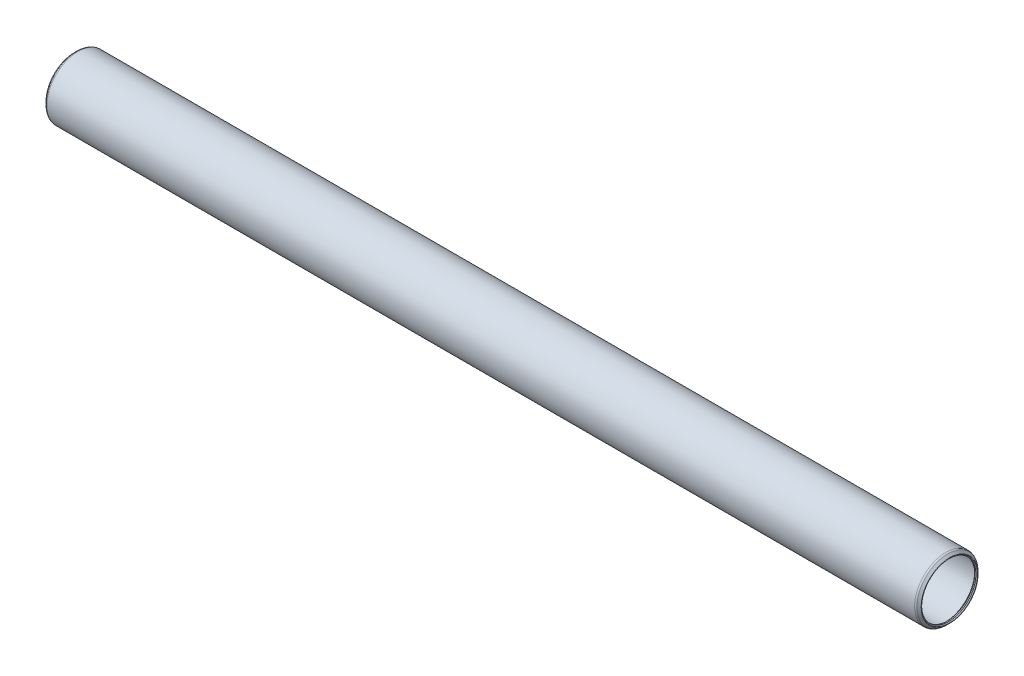
from build123d import *


with BuildPart() as part:
    # Sketch1 → Revolve1 (revolve)
    with BuildSketch(Plane.XY):
        with BuildLine():
            Line((-0.639512806, 9.167562806), (-0.381, 8.90905))
            Line((-0.381, 8.90905), (0, 8.90905))
            Line((0, 8.90905), (0.762, 9.67105))
            Line((0.762, 9.67105), (285.1277, 9.67105))
            Line((285.1277, 9.67105), (285.8897, 8.90905))
            Line((285.8897, 8.90905), (286.2707, 8.90905))
            Line((286.2707, 8.90905), (286.529212806, 9.167562806))
            ThreePointArc((286.529212806, 9.167562806), (286.566410245, 9.257365367), (286.529212806, 9.347167928))
            Line((286.529212806, 9.347167928), (285.844315367, 10.032065367))
            ThreePointArc((285.844315367, 10.032065367), (285.597104775, 10.197246204), (285.3055, 10.25525))
            Line((285.3055, 10.25525), (0.5842, 10.25525))
            ThreePointArc((0.5842, 10.25525), (0.292595225, 10.197246204), (0.045384633, 10.032065367))
            Line((0.045384633, 10.032065367), (-0.639512806, 9.347167928))
            ThreePointArc((-0.639512806, 9.347167928), (-0.676710245, 9.257365367), (-0.639512806, 9.167562806))
        make_face()
    revolve(axis=Axis((285.8897, 0, 0), (-1, 0, 0)))


solid = part.part
